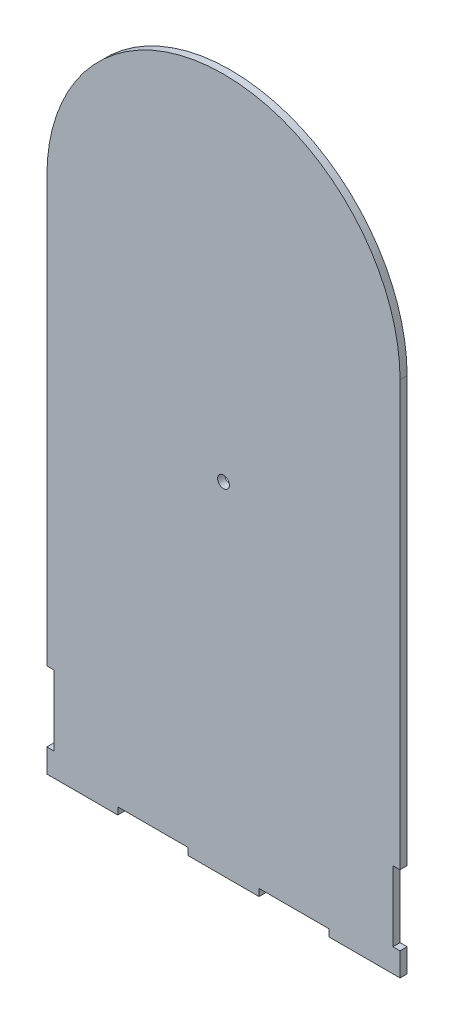
from build123d import *

# Parameters (mm, degrees)
SKETCH1_R           = 2.5
BOSS_EXTRUDE1_DEPTH = 3


with BuildPart() as part:
    # Sketch1 → Boss-Extrude1 (new body)
    with BuildSketch(Plane.XY):
        with BuildLine():
            Line((59.9, 0), (90.1, 0))
            Line((90.1, 0), (90.1, 3))
            Line((90.1, 3), (119.9, 3))
            Line((119.9, 3), (119.9, 0))
            Line((119.9, 0), (150, 0))
            Line((150, 0), (150, 10))
            Line((150, 10), (147, 10))
            Line((147, 10), (147, 39.8))
            Line((147, 39.8), (150, 39.8))
            Line((150, 39.8), (150, 220))
            ThreePointArc((150, 220), (75, 295), (0, 220))
            Line((0, 220), (0, 39.8))
            Line((0, 39.8), (3, 39.8))
            Line((3, 39.8), (3, 10))
            Line((3, 10), (0, 10))
            Line((0, 10), (0, 0))
            Line((0, 0), (30.1, 0))
            Line((30.1, 0), (30.1, 3))
            Line((30.1, 3), (59.9, 3))
            Line((59.9, 3), (59.9, 0))
        make_face()
        with Locations((75, 145)):
            Circle(SKETCH1_R, mode=Mode.SUBTRACT)
    extrude(amount=BOSS_EXTRUDE1_DEPTH)


solid = part.part
